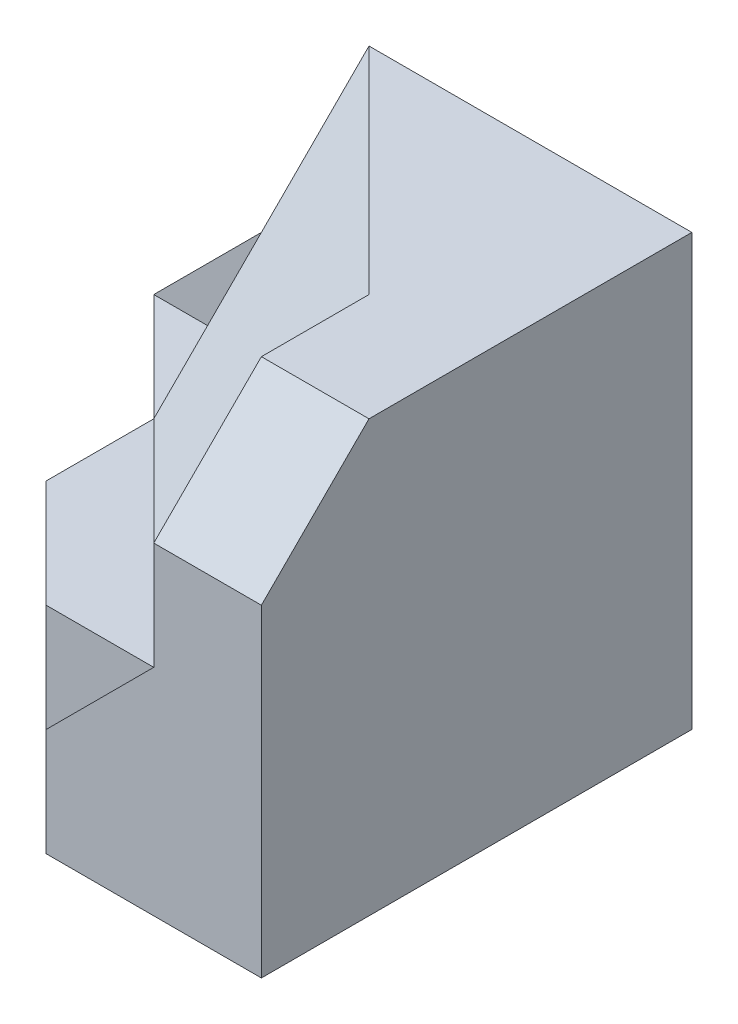
from build123d import *

# Parameters (mm, degrees)
BOSS_EXTRUDE1_DEPTH  = 20
SKETCH2_W            = 5
SKETCH2_H            = 20
BOSS_EXTRUDE2_DEPTH  = 5
CUT_EXTRUDE1_DEPTH   = 5
SKETCH4_W            = 5
SKETCH4_H            = 10
BOSS_EXTRUDE3_DEPTH  = 5
CUT_EXTRUDE2_DEPTH   = 5
BOSS_EXTRUDE31_DEPTH = 20
CUT_EXTRUDE11_DEPTH  = 25
SKETCH24_W           = 5
SKETCH24_H           = 15
BOSS_EXTRUDE32_DEPTH = 5
CUT_EXTRUDE12_DEPTH  = 5
BOSS_EXTRUDE33_DEPTH = 5
BOSS_EXTRUDE34_DEPTH = 5


with BuildPart() as part:
    # Sketch1 → Boss-Extrude1 (new body)
    with BuildSketch(Plane(origin=(0, 0, 0), x_dir=(1, 0, 0), z_dir=(0, 1, 0))):
        Polygon((-15, 0), (0, 0), (0, -15), (-5, -15), (-5, -10), align=None)
    extrude(amount=-BOSS_EXTRUDE1_DEPTH)

    # Sketch2 → Boss-Extrude2 (add)
    with BuildSketch(Plane.XY.offset(15)):
        with Locations((-2.5, -10)):
            Rectangle(SKETCH2_W, SKETCH2_H)
    extrude(amount=BOSS_EXTRUDE2_DEPTH)

    # Sketch3 → Cut-Extrude1 (cut)
    with BuildSketch(Plane.ZY.offset(5)):
        Polygon((15, 0), (20, -5), (20, 0), align=None)
    extrude(amount=-CUT_EXTRUDE1_DEPTH, mode=Mode.SUBTRACT)

    # Sketch4 → Boss-Extrude3 (add)
    with BuildSketch(Plane.ZY.offset(5)):
        with Locations((17.5, -15)):
            Rectangle(SKETCH4_W, SKETCH4_H)
    extrude(amount=BOSS_EXTRUDE3_DEPTH)

    # Sketch5 → Cut-Extrude2 (cut)
    with BuildSketch(Plane.XY.offset(20)):
        Polygon((-5, -10), (-10, -15), (-10, -10), align=None)
    extrude(amount=-CUT_EXTRUDE2_DEPTH, mode=Mode.SUBTRACT)

    # Sketch14 → Boss-Extrude31 (add)
    with BuildSketch(Plane(origin=(0, -20, 0), x_dir=(-1, 0, 0), z_dir=(0, -1, 0))):
        Polygon((15, 0), (5, -10), (5, -15), (10, -15), (15, -10), align=None)
    extrude(amount=-BOSS_EXTRUDE31_DEPTH)

    # 3DSketch7 → Cut-Extrude11 (cut, along a direction that is not the sketch's normal)
    with BuildSketch(Plane(origin=(-15, 0, 0), x_dir=(0.5345224838248488, -0.2672612419124244, 0.8017837257372732), z_dir=(0.5773502691896258, -0.5773502691896258, -0.5773502691896258))):
        Polygon((0, 0), (13.363062096, -4.629100499), (18.708286934, 0), (17.371980724, 6.943650748), (10.690449676, 9.258200998), align=None)
    extrude(amount=-CUT_EXTRUDE11_DEPTH, dir=(0, 0, -1), mode=Mode.SUBTRACT)

    # Sketch24 → Boss-Extrude32 (add)
    with BuildSketch(Plane.ZY.offset(15)):
        with Locations((2.5, -12.5)):
            Rectangle(SKETCH24_W, SKETCH24_H)
    extrude(amount=BOSS_EXTRUDE32_DEPTH)

    # Sketch25 → Cut-Extrude12 (cut)
    with BuildSketch(Plane.XY.offset(5)):
        Polygon((-15, -5), (-20, -5), (-20, -10), align=None)
    extrude(amount=-CUT_EXTRUDE12_DEPTH, mode=Mode.SUBTRACT)

    # Sketch26 → Boss-Extrude33 (add)
    with BuildSketch(Plane(origin=(0, -20, 0), x_dir=(-1, 0, 0), z_dir=(0, -1, 0))):
        Polygon((20, -5), (15, -5), (15, -10), (10, -15), (15, -15), (20, -10), align=None)
    extrude(amount=-BOSS_EXTRUDE33_DEPTH)

    # Sketch27 → Boss-Extrude34 (add)
    with BuildSketch(Plane(origin=(0, -15, 0), x_dir=(1, 0, 0), z_dir=(0, 1, 0))):
        Polygon((-20, -5), (-15, -5), (-15, -10), align=None)
    extrude(amount=BOSS_EXTRUDE34_DEPTH)


solid = part.part
